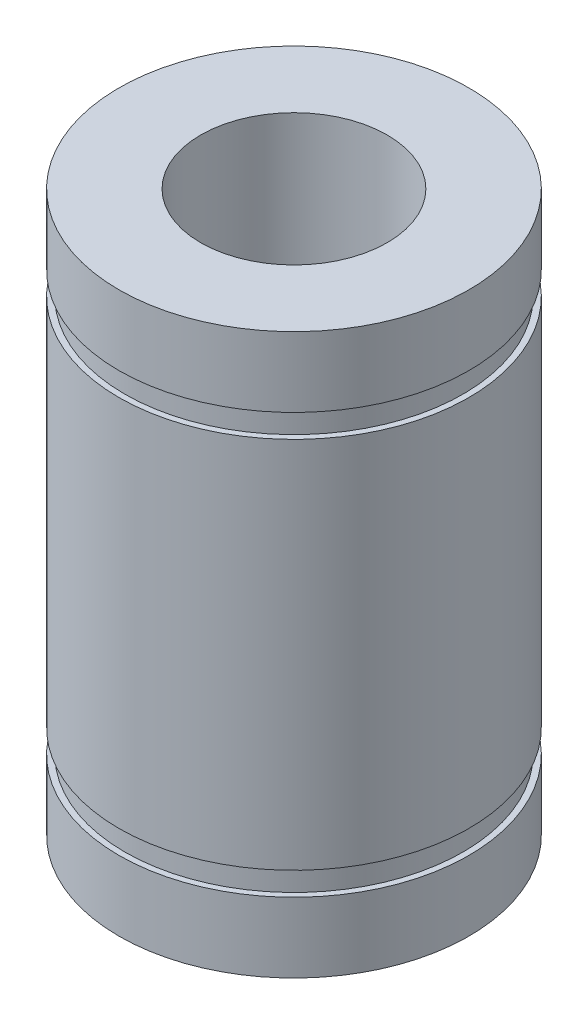
from build123d import *


with BuildPart() as part:
    # Esboço1 → Revolução1 (revolve)
    with BuildSketch(Plane.XY):
        Polygon((4, 0), (7.5, 0), (7.5, -3), (7.25, -3), (7.25, -4), (7.5, -4), (7.5, -20), (7.25, -20), (7.25, -21), (7.5, -21), (7.5, -24), (4, -24), align=None)
    revolve(axis=Axis((0, 0, 0), (0, -1, 0)))


solid = part.part
